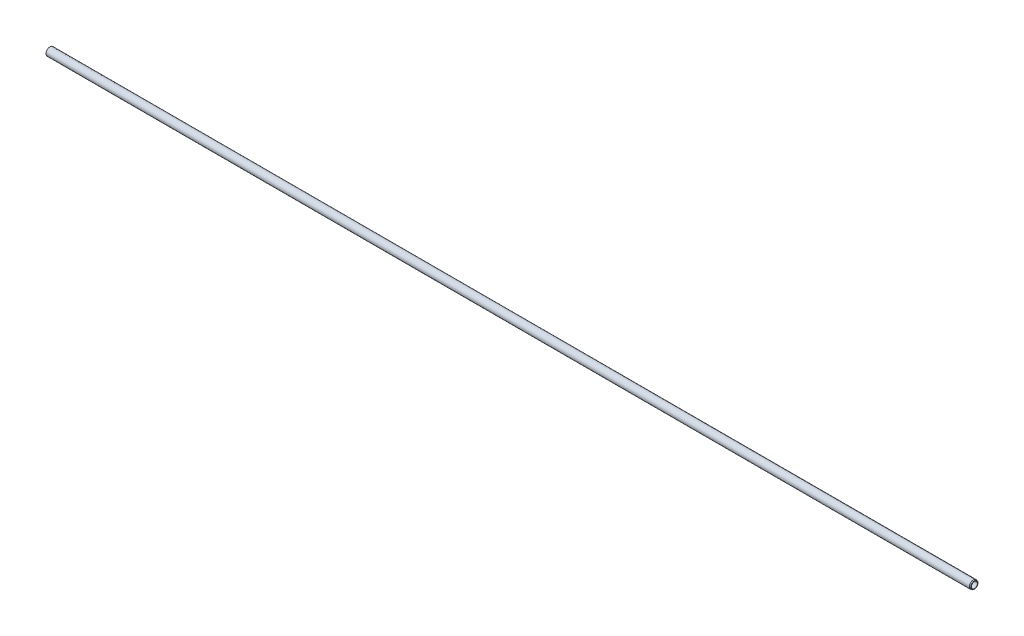
from build123d import *


with BuildPart() as part:
    # Sketch1 → Base-Revolve (revolve)
    with BuildSketch(Plane.XY):
        Polygon((0, 10), (0, 7.5), (2312, 7.5), (2312, 9.090074414), (2309.5, 10), align=None)
    revolve(axis=Axis((0, 0, 0), (1, 0, 0)))


solid = part.part
